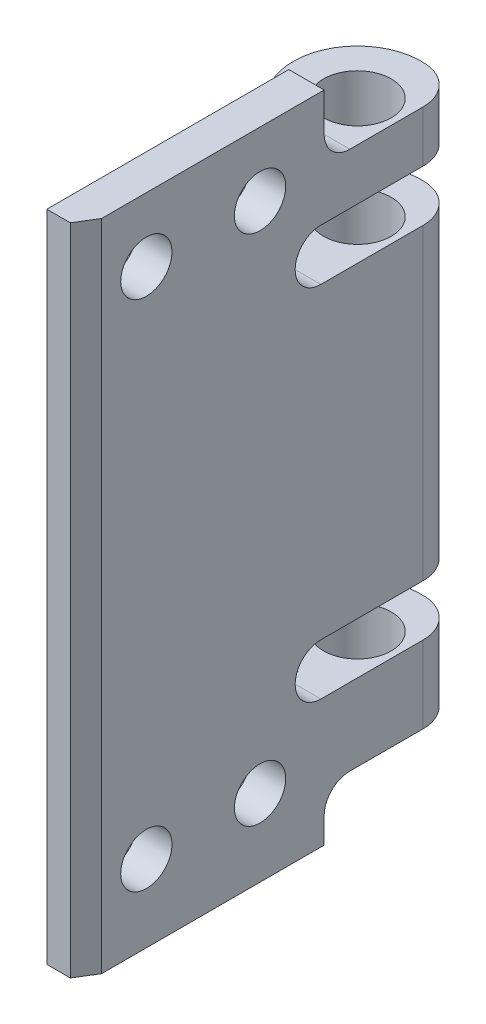
from build123d import *

# Parameters (mm, degrees)
BOSS_EXTRUDE5_DEPTH          = 2.760049195
CHAMFER1_SIZE                = 1.510362865
CHAMFER1_SIZE2               = 0.926037145
BOSS_EXTRUDE6_DEPTH          = 24
BOSS_EXTRUDE7_DEPTH          = 5
BOSS_EXTRUDE8_DEPTH          = 6
BOSS_EXTRUDE9_DEPTH          = 4
SKETCH28_W                   = 2.760049196
SKETCH28_H                   = 4
CUT_EXTRUDE3_DEPTH           = 8.878692186
BOSS_EXTRUDE10_DEPTH         = 4
SKETCH45_W                   = 2.760049196
SKETCH45_H                   = 4
CUT_EXTRUDE4_DEPTH           = 0.7448337
BOSS_EXTRUDE11_DEPTH         = 5
F_4_0_4_DIAMETER_HOLE2_D     = 4
F_4_0_4_DIAMETER_HOLE2_DEPTH = 2.760049195
SKETCH58_W                   = 2.6375
SKETCH58_H                   = 10
SKETCH60_W                   = 2.6375
SKETCH60_H                   = 38
HOLE6_D                      = 5.275
HOLE6_DEPTH                  = 46
F_3_0_3_DIAMETER_HOLE2_D     = 3
F_3_0_3_DIAMETER_HOLE2_DEPTH = 35
FILLET3_R                    = 2
FILLET4_R                    = 3


with BuildPart() as part:
    # Sketch17 → Boss-Extrude5 (new body)
    with BuildSketch(Plane(origin=(57.196631886, 0, 0), x_dir=(0, -1, 0), z_dir=(-1, 0, 0))):
        with BuildLine():
            Line((-38, -27.633835998), (-14, -27.633835998))
            ThreePointArc((-14, -27.633835998), (-12, -25.633835998), (-10, -27.633835998))
            Line((-10, -27.633835998), (-10, -9.028355512))
            Line((-10, -9.028355512), (-42, -9.028355512))
            Line((-42, -9.028355512), (-42, -27.633835998))
            ThreePointArc((-42, -27.633835998), (-40, -25.633835998), (-38, -27.633835998))
        make_face()
    extrude(amount=-BOSS_EXTRUDE5_DEPTH)

    # Chamfer1
    chamfer1_edges = [part.edges().sort_by_distance(p)[0] for p in [
        (59.956681082, 26, -9.028355512),
    ]]
    chamfer1_side = [part.faces().sort_by_distance(p)[0] for p in [
        (59.956681082, 26, -18.148814744),
    ]]
    chamfer(chamfer1_edges, length=CHAMFER1_SIZE, length2=CHAMFER1_SIZE2, reference=chamfer1_side[0])

    # Sketch18 → Boss-Extrude6 (add)
    with BuildSketch(Plane(origin=(0, 38, 0), x_dir=(1, 0, 0), z_dir=(0, 1, 0))):
        with BuildLine():
            Line((57.196631886, 27.633835998), (59.956681082, 27.633835998))
            Line((59.956681082, 27.633835998), (59.956681082, 37.518663649))
            ThreePointArc((59.956681082, 37.518663649), (52.044420209, 35.109942461), (57.196631886, 28.639971463))
            Line((57.196631886, 28.639971463), (57.196631886, 27.633835998))
        make_face()
    extrude(amount=-BOSS_EXTRUDE6_DEPTH)

    # Sketch19 → Boss-Extrude7 (add)
    with BuildSketch(Plane(origin=(0, 35, 0), x_dir=(1, 0, 0), z_dir=(0, 1, 0))):
        with BuildLine():
            Line((57.196631886, 15.88036097), (57.196631886, 23.207838196))
            add(Edge.make_bspline(
                [(55.511713205, 21.752088745), (56.732163203, 22.065636669), (57.196631886, 23.207838196)],
                knots=[0, 0, 0, 1, 1, 1], degree=2))
            ThreePointArc((55.511713205, 21.752088745), (53.511713205, 19.752088745), (55.511713205, 17.752088745))
            add(Edge.make_bspline(
                [(57.196631886, 15.88036097), (56.909946197, 17.31678815), (55.511713205, 17.752088745)],
                knots=[0, 0, 0, 1, 1, 1], degree=2))
        make_face()
    extrude(amount=-BOSS_EXTRUDE7_DEPTH)

    # Sketch20 → Boss-Extrude8 (add)
    with BuildSketch(Plane.XZ.offset(-10)):
        with BuildLine():
            Line((57.196631886, -28.639971463), (57.196631886, -9.028355512))
            Line((57.196631886, -9.028355512), (59.030643937, -9.028355512))
            Line((59.030643937, -9.028355512), (59.956681082, -10.538718377))
            Line((59.956681082, -10.538718377), (59.956681082, -37.518663649))
            ThreePointArc((59.956681082, -37.518663649), (52.044420209, -35.109942461), (57.196631886, -28.639971463))
        make_face()
    extrude(amount=BOSS_EXTRUDE8_DEPTH)

    # Sketch21 → Boss-Extrude9 (add)
    with BuildSketch(Plane.XZ.offset(-4)):
        Polygon((57.196631886, -27.895137764), (57.196631886, -9.028355512), (59.030643937, -9.028355512), (59.956681082, -10.538718377), (59.956681082, -27.895137764), (59.956681082, -28.639971463), (59.956681082, -37.518663649), (57.196631886, -37.518663649), (57.196631886, -28.639971463), align=None)
    extrude(amount=BOSS_EXTRUDE9_DEPTH)

    # Sketch28 → Cut-Extrude3 (cut)
    with BuildSketch(Plane(origin=(0, 0, -37.518663649), x_dir=(-1, 0, 0), z_dir=(0, 0, -1))):
        with Locations((-58.576656484, 2)):
            Rectangle(SKETCH28_W, SKETCH28_H)
    extrude(amount=-CUT_EXTRUDE3_DEPTH, mode=Mode.SUBTRACT)

    # Sketch36 → Boss-Extrude10 (add)
    with BuildSketch(Plane(origin=(0, 42, 0), x_dir=(1, 0, 0), z_dir=(0, 1, 0))):
        with BuildLine():
            Line((59.956681082, 37.518663649), (59.956681082, 10.538718377))
            Line((59.956681082, 10.538718377), (59.030643937, 9.028355512))
            Line((59.030643937, 9.028355512), (57.196631886, 9.028355512))
            Line((57.196631886, 9.028355512), (57.196631886, 28.639971463))
            ThreePointArc((57.196631886, 28.639971463), (52.044420209, 35.109942461), (59.956681082, 37.518663649))
        make_face()
    extrude(amount=BOSS_EXTRUDE10_DEPTH)

    # Sketch45 → Cut-Extrude4 (cut)
    with BuildSketch(Plane(origin=(0, 0, -28.639971463), x_dir=(-1, 0, 0), z_dir=(0, 0, -1))):
        with Locations((-58.576656484, 2)):
            Rectangle(SKETCH45_W, SKETCH45_H)
    extrude(amount=-CUT_EXTRUDE4_DEPTH, mode=Mode.SUBTRACT)

    # Sketch55 → Boss-Extrude11 (add)
    with BuildSketch(Plane(origin=(0, 46, 0), x_dir=(1, 0, 0), z_dir=(0, 1, 0))):
        Polygon((59.956681082, 10.538718377), (59.030643937, 9.028355512), (57.196631886, 9.028355512), (57.196631886, 27.895137764), (59.956681082, 27.895137764), align=None)
    extrude(amount=BOSS_EXTRUDE11_DEPTH)

    # Ø4.0 (4) Diameter Hole2
    with Locations(Plane.ZY.offset(-57.196631886)):
        with Locations((-22.895137764, 6), (-14.028355512, 6), (-14.028355512, 46), (-22.895137764, 46)):
            Hole(F_4_0_4_DIAMETER_HOLE2_D / 2, depth=F_4_0_4_DIAMETER_HOLE2_DEPTH)

    # Sketch58 → Hole4 (revolve, cut)
    with BuildSketch(Plane(origin=(56.81904117, 10, -33.625693603), x_dir=(0, 0, 1), z_dir=(1, 0, 0))):
        with Locations((1.31875, 5)):
            Rectangle(SKETCH58_W, SKETCH58_H)
    revolve(axis=Axis((56.81904117, -100, -33.625693603), (0, 1, 0)), mode=Mode.SUBTRACT)

    # Sketch60 → Hole5 (revolve, cut)
    with BuildSketch(Plane(origin=(56.81904117, 38, -33.625693603), x_dir=(0, 0, 1), z_dir=(1, 0, 0))):
        with Locations((1.31875, 19)):
            Rectangle(SKETCH60_W, SKETCH60_H)
    revolve(axis=Axis((56.81904117, -72, -33.625693603), (0, 1, 0)), mode=Mode.SUBTRACT)

    # Hole6
    with Locations(Plane(origin=(0, 46, 0), x_dir=(1, 0, 0), z_dir=(0, 1, 0))):
        with Locations((56.81904117, 33.625693603)):
            Hole(HOLE6_D / 2, depth=HOLE6_DEPTH)

    # Ø3.0 (3) Diameter Hole2
    with Locations(Plane(origin=(0, 35, 0), x_dir=(1, 0, 0), z_dir=(0, 1, 0))):
        with Locations((55.511713205, 19.752088745)):
            Hole(F_3_0_3_DIAMETER_HOLE2_D / 2, depth=F_3_0_3_DIAMETER_HOLE2_DEPTH)

    # Fillet3
    fillet3_edges = [part.edges().sort_by_distance(p)[0] for p in [
        (58.576656484, 46, -27.895137764),
        (58.576656484, 4, -27.895137764),
        (57.196631886, 26, -28.639971463),
    ]]
    fillet(fillet3_edges, radius=FILLET3_R)

    # Fillet4
    fillet4_edges = [part.edges().sort_by_distance(p)[0] for p in [
        (59.956681082, 26, -37.518663649),
        (59.956681082, 7, -37.518663649),
        (59.956681082, 44, -37.518663649),
    ]]
    fillet(fillet4_edges, radius=FILLET4_R)


solid = part.part
